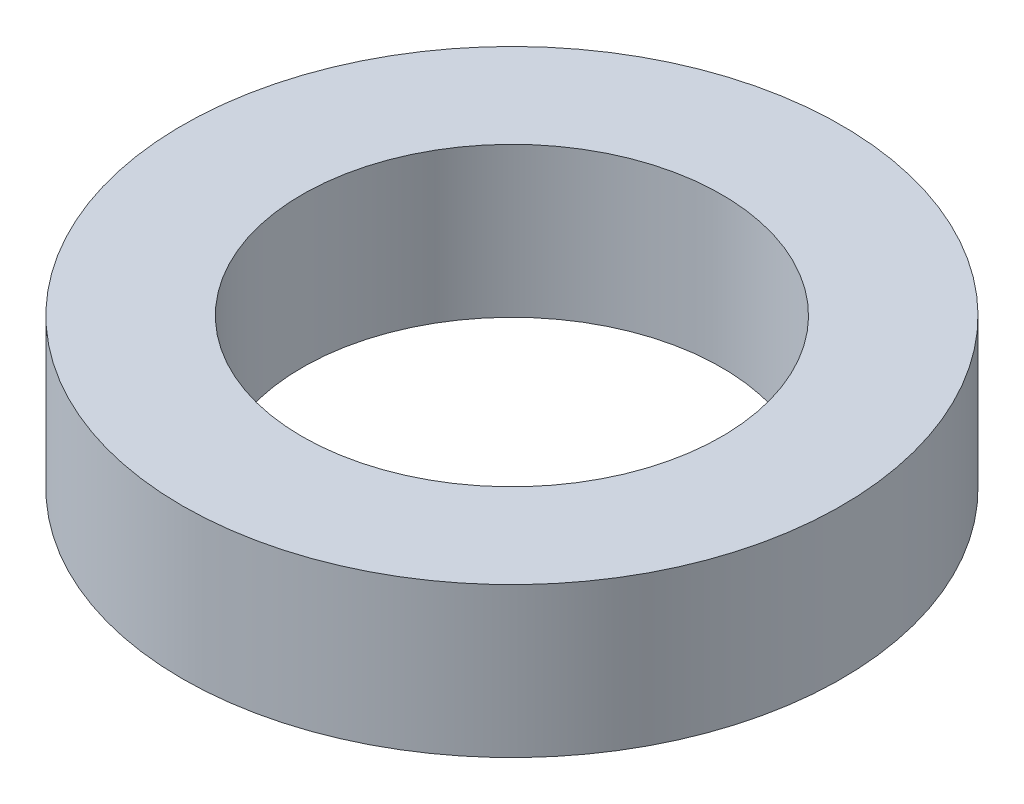
from build123d import *

# Parameters (mm, degrees)
SKETCH_1_R      = 5.5
SKETCH_1_R_2    = 3.5
EXTRUDE_1_DEPTH = 2.5


with BuildPart() as part:
    # 草图1 → 凸台-拉伸1 (new body)
    with BuildSketch(Plane(origin=(0, 0, 0), x_dir=(1, 0, 0), z_dir=(0, 1, 0))):
        Circle(SKETCH_1_R)
        Circle(SKETCH_1_R_2, mode=Mode.SUBTRACT)
    extrude(amount=EXTRUDE_1_DEPTH)


solid = part.part
